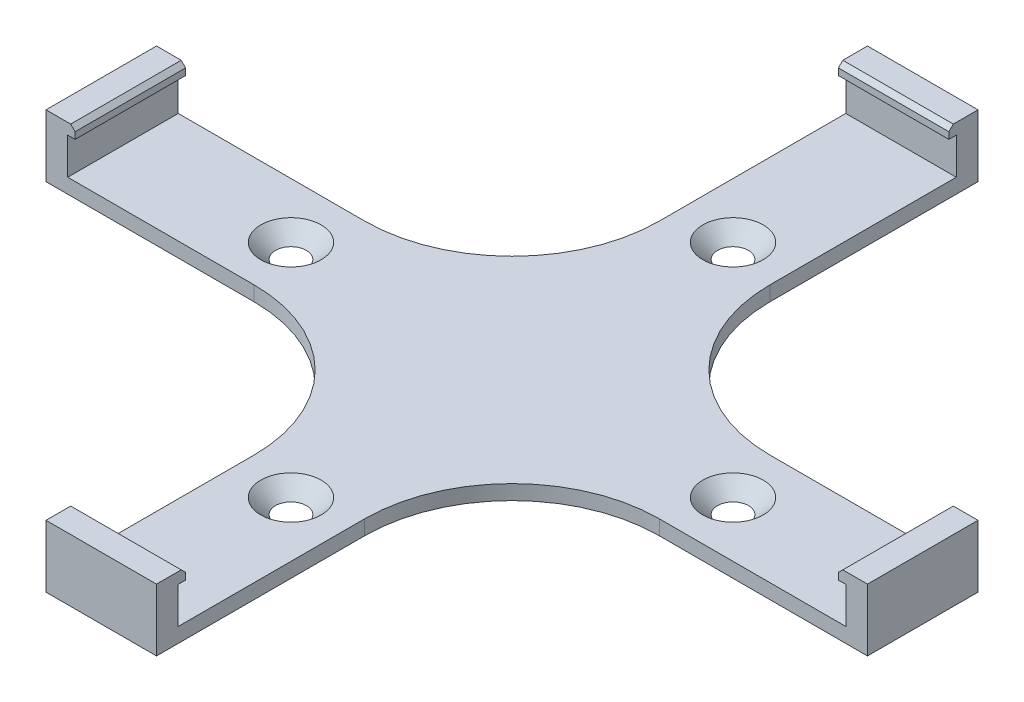
from build123d import *

# Parameters (mm, degrees)
BOSS_EXTRUDE1_DEPTH                            = 2
BOSS_EXTRUDE3_DEPTH                            = 15
BOSS_EXTRUDE4_DEPTH                            = 15
CSK_FOR_M3_5_FLAT_HEAD_MACHINE_SCREW1_AT_COUNT = 2
CSK_FOR_M3_5_FLAT_HEAD_MACHINE_SCREW1_AT_PITCH = 42.426406871
CSK_FOR_M3_5_FLAT_HEAD_MACHINE_SCREW_2_COUNT   = 2
CSK_FOR_M3_5_FLAT_HEAD_MACHINE_SCREW_2_PITCH   = 60
CSK_FOR_M3_5_FLAT_HEAD_MACHINE_SCREW_3_COUNT   = 2
CSK_FOR_M3_5_FLAT_HEAD_MACHINE_SCREW_3_PITCH   = 42.426406871


with BuildPart() as part:
    # Sketch1 → Boss-Extrude1 (new body)
    with BuildSketch(Plane(origin=(0, 0, 0), x_dir=(1, 0, 0), z_dir=(0, 1, 0))):
        with BuildLine():
            Line((-7.5, 55.75), (-7.5, 27.5))
            ThreePointArc((-7.5, 27.5), (-13.357864376, 13.357864376), (-27.5, 7.5))
            Line((-27.5, 7.5), (-55.75, 7.5))
            Line((-55.75, 7.5), (-55.75, -7.5))
            Line((-55.75, -7.5), (-27.5, -7.5))
            ThreePointArc((-27.5, -7.5), (-13.357864376, -13.357864376), (-7.5, -27.5))
            Line((-7.5, -27.5), (-7.5, -55.75))
            Line((-7.5, -55.75), (7.5, -55.75))
            Line((7.5, -55.75), (7.5, -27.5))
            ThreePointArc((7.5, -27.5), (13.357864376, -13.357864376), (27.5, -7.5))
            Line((27.5, -7.5), (55.75, -7.5))
            Line((55.75, -7.5), (55.75, 7.5))
            Line((55.75, 7.5), (27.5, 7.5))
            ThreePointArc((27.5, 7.5), (13.357864376, 13.357864376), (7.5, 27.5))
            Line((7.5, 27.5), (7.5, 55.75))
            Line((7.5, 55.75), (-7.5, 55.75))
        make_face()
    extrude(amount=BOSS_EXTRUDE1_DEPTH)

    # Sketch3 → Boss-Extrude3 (add)
    with BuildSketch(Plane(origin=(7.5, 0, 0), x_dir=(0, 0, -1), z_dir=(1, 0, 0))):
        Polygon((55.75, 2), (55.75, 8.45), (52.4, 8.45), (51.8, 7.85), (51.8, 6.95), (52.8, 6.95), (52.8, 2), align=None)
    boss_extrude3 = extrude(amount=-BOSS_EXTRUDE3_DEPTH)

    # Mirror1: Boss-Extrude3 across plane
    add(boss_extrude3.mirror(Plane.XY))

    # Sketch6 → Boss-Extrude4 (add)
    with BuildSketch(Plane(origin=(0, 0, -7.5), x_dir=(-1, 0, 0), z_dir=(0, 0, -1))):
        Polygon((55.75, 2), (55.75, 8.45), (52.4, 8.45), (51.8, 7.85), (51.8, 6.95), (52.8, 6.95), (52.8, 2), align=None)
    boss_extrude4 = extrude(amount=-BOSS_EXTRUDE4_DEPTH)

    # Mirror2: Boss-Extrude4 across plane
    add(boss_extrude4.mirror(Plane(origin=(0, 0, 0), x_dir=(0, 0, 1), z_dir=(1, 0, 0))))

    # Sketch9 → CSK for M3.5 Flat Head Machine Screw1 (revolve, cut)
    with BuildSketch(Plane(origin=(0, 2, 30), x_dir=(0, 0, 1), z_dir=(1, 0, 0))):
        Polygon((0, 0), (0, 2), (1.95, 2), (1.95, 2.15), (4.1, 0), align=None)
    csk_for_m3_5_flat_head_machine_screw1 = revolve(axis=Axis((0, 8.35, 30), (0, -1, 0)), mode=Mode.SUBTRACT)

    # CSK for M3.5 Flat Head Machine Screw1 at: CSK for M3.5 Flat Head Machine Screw1 ×2
    with Locations(*[Vector(-0.707106781, 0, -0.707106781) * (i * CSK_FOR_M3_5_FLAT_HEAD_MACHINE_SCREW1_AT_PITCH) for i in range(1, CSK_FOR_M3_5_FLAT_HEAD_MACHINE_SCREW1_AT_COUNT)]):
        add(csk_for_m3_5_flat_head_machine_screw1, mode=Mode.SUBTRACT)

    # CSK for M3.5 Flat Head Machine Screw 2: CSK for M3.5 Flat Head Machine Screw1 ×2
    with Locations(*[(0, 0, -i * CSK_FOR_M3_5_FLAT_HEAD_MACHINE_SCREW_2_PITCH) for i in range(1, CSK_FOR_M3_5_FLAT_HEAD_MACHINE_SCREW_2_COUNT)]):
        add(csk_for_m3_5_flat_head_machine_screw1, mode=Mode.SUBTRACT)

    # CSK for M3.5 Flat Head Machine Screw 3: CSK for M3.5 Flat Head Machine Screw1 ×2
    with Locations(*[Vector(0.707106781, 0, -0.707106781) * (i * CSK_FOR_M3_5_FLAT_HEAD_MACHINE_SCREW_3_PITCH) for i in range(1, CSK_FOR_M3_5_FLAT_HEAD_MACHINE_SCREW_3_COUNT)]):
        add(csk_for_m3_5_flat_head_machine_screw1, mode=Mode.SUBTRACT)


solid = part.part
